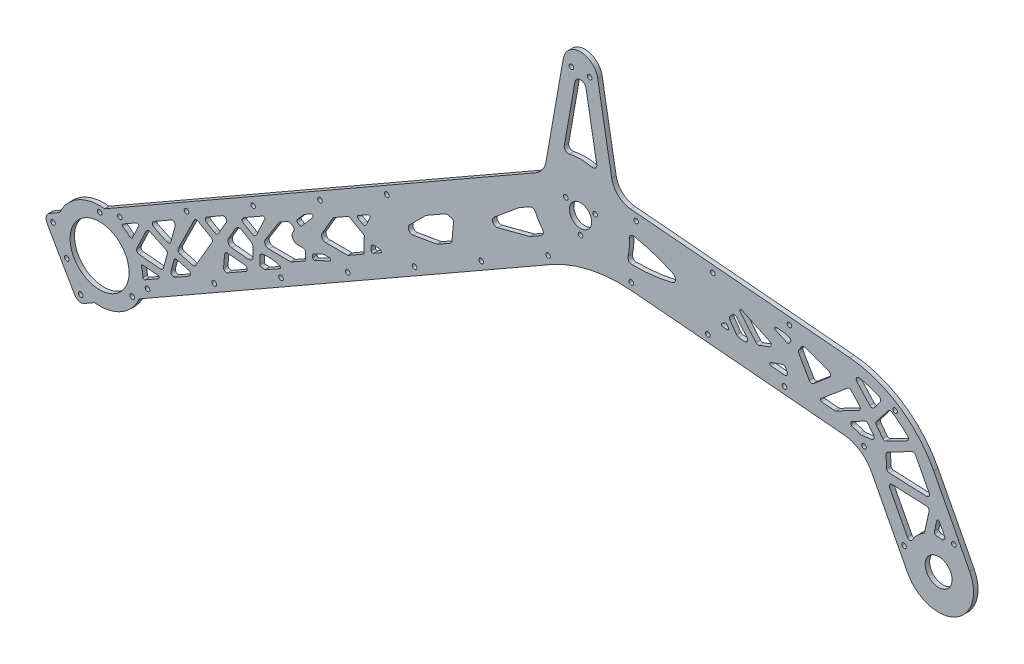
from build123d import *

# Parameters (mm, degrees)
SKETCH2_R                 = 7.9375
SKETCH2_R_2               = 16.05
SKETCH2_R_3               = 1.65
SKETCH2_R_4               = 9.5885
BASE_DEPTH                = 3.175
SKETCH3_R                 = 1.65
STRUT_HOLES_DEPTH         = 4.175
LIGHTENING_HOLES_DEPTH    = 4.175
SKETCH7_R                 = 31.1
SKETCH7_R_2               = 21.1
INNER_MOD_EXTRUSION_DEPTH = 3.175
SKETCH7_2_R               = 21.1
INNER_MOD_CUT_DEPTH       = 4.175
SKETCH8_R                 = 1.65
CUT_EXTRUDE1_DEPTH        = 4.175
FILLET1_R                 = 1
SKETCH9_R                 = 1.65
CUT_EXTRUDE2_DEPTH        = 4.175


with BuildPart() as part:
    # Sketch2 → Base (new body)
    with BuildSketch(Plane.XY):
        with BuildLine():
            Line((-379.716809958, -188.506893436), (-32.006532147, 10.487277971))
            ThreePointArc((-32.006532147, 10.487277971), (-27.186230121, 14.879084252), (-24.685038782, 20.901319377))
            Line((-24.685038782, 20.901319377), (-12.310096913, 91.083102221))
            ThreePointArc((-12.310096913, 91.083102221), (0, 101.4125), (12.310096913, 91.083102221))
            Line((12.310096913, 91.083102221), (22.322003955, 34.302755831))
            ThreePointArc((22.322003955, 34.302755831), (26.960267136, 25.848318444), (35.786784109, 21.964558025))
            Line((35.786784109, 21.964558025), (192.586144941, 8.246391504))
            ThreePointArc((192.586144941, 8.246391504), (227.717231711, -4.10798993), (252.575276723, -31.83706486))
            Line((252.575276723, -31.83706486), (278.255270829, -81.167874559))
            ThreePointArc((278.255270829, -81.167874559), (267.623715331, -114.886860719), (233.904729171, -104.255305221))
            Line((233.904729171, -104.255305221), (208.224735064, -54.924495522))
            ThreePointArc((208.224735064, -54.924495522), (199.93872006, -45.681470545), (188.228357804, -41.563343401))
            Line((188.228357804, -41.563343401), (36.823729736, -28.317154839))
            ThreePointArc((36.823729736, -28.317154839), (6.649577682, -30.266109959), (-21.562664076, -41.144864173))
            Line((-21.562664076, -41.144864173), (-354.881400189, -231.902773674))
            ThreePointArc((-354.881400189, -231.902773674), (-358.677364619, -232.387866435), (-361.70452919, -230.046726627))
            Line((-361.70452919, -230.046726627), (-381.572857005, -195.330022437))
            ThreePointArc((-381.572857005, -195.330022437), (-382.057949767, -191.534058007), (-379.716809958, -188.506893436))
        make_face()
        Circle(SKETCH2_R, mode=Mode.SUBTRACT)
        with Locations((-343.92, -196.825)):
            Circle(SKETCH2_R_2, mode=Mode.SUBTRACT)
        with Locations((-6.5, 88.9125)):
            Circle(SKETCH2_R_3, mode=Mode.SUBTRACT)
        with Locations((6.5, 88.9125)):
            Circle(SKETCH2_R_3, mode=Mode.SUBTRACT)
        with Locations((256.08, -92.71158989)):
            Circle(SKETCH2_R_4, mode=Mode.SUBTRACT)
        with Locations((-365.631063534, -190.919094461)):
            Circle(SKETCH2_R_3, mode=Mode.SUBTRACT)
        with Locations((-338.014094461, -175.113936466)):
            Circle(SKETCH2_R_3, mode=Mode.SUBTRACT)
        with Locations((-322.208936466, -202.730905539)):
            Circle(SKETCH2_R_3, mode=Mode.SUBTRACT)
        with Locations((-349.825905539, -218.536063534)):
            Circle(SKETCH2_R_3, mode=Mode.SUBTRACT)
    extrude(amount=BASE_DEPTH)

    # Sketch3 → Strut Holes (cut, through all)
    with BuildSketch(Plane.XY.offset(3.175)):
        with Locations((-357.364941166, -227.56318565)):
            Circle(SKETCH3_R)
        with Locations((-309.629472905, -200.244234904)):
            Circle(SKETCH3_R)
        with Locations((-261.894004643, -172.925284158)):
            Circle(SKETCH3_R)
        with Locations((-214.158536382, -145.606333412)):
            Circle(SKETCH3_R)
        with Locations((-166.42306812, -118.287382666)):
            Circle(SKETCH3_R)
        with Locations((-118.687599859, -90.96843192)):
            Circle(SKETCH3_R)
        with Locations((-329.49780072, -165.527530714)):
            Circle(SKETCH3_R)
        with Locations((-377.233268981, -192.84648146)):
            Circle(SKETCH3_R)
        with Locations((-281.762332458, -138.208579968)):
            Circle(SKETCH3_R)
        with Locations((-234.026864197, -110.889629222)):
            Circle(SKETCH3_R)
        with Locations((-186.291395936, -83.570678476)):
            Circle(SKETCH3_R)
        with Locations((-138.555927674, -56.25172773)):
            Circle(SKETCH3_R)
        with Locations((36.307361546, -23.252879289)):
            Circle(SKETCH3_R)
        with Locations((91.098069941, -28.04644514)):
            Circle(SKETCH3_R)
        with Locations((145.888778336, -32.840010991)):
            Circle(SKETCH3_R)
        with Locations((149.375008046, 7.007776933)):
            Circle(SKETCH3_R)
        with Locations((94.584299651, 11.801342784)):
            Circle(SKETCH3_R)
        with Locations((39.793591256, 16.594908635)):
            Circle(SKETCH3_R)
        with Locations((-70.952131597, -63.649481174)):
            Circle(SKETCH3_R)
        with Locations((-23.216663336, -36.330530428)):
            Circle(SKETCH3_R)
        with Locations((202.716571226, -41.524122484)):
            Circle(SKETCH3_R)
        with Locations((224.939380546, -8.265337992)):
            Circle(SKETCH3_R)
        with Locations((231.413554138, -88.641399657)):
            Circle(SKETCH3_R)
        with Locations((266.893987465, -70.171455127)):
            Circle(SKETCH3_R)
    extrude(amount=-STRUT_HOLES_DEPTH, mode=Mode.SUBTRACT)

    # Sketch6 → Lightening Holes (cut, through all)
    with BuildSketch(Plane.XY.offset(3.175)):
        with BuildLine():
            Line((-315.269185897, -197.710920307), (-301.759255291, -189.979203363))
            ThreePointArc((-301.759255291, -189.979203363), (-301.27885272, -188.89855459), (-302.165025934, -188.115429161))
            Line((-302.165025934, -188.115429161), (-317.529091672, -186.71244549))
            ThreePointArc((-317.529091672, -186.71244549), (-318.704383169, -186.968323474), (-319.520360019, -187.852045956))
            Line((-319.520360019, -187.852045956), (-321.920665487, -192.94890269))
            ThreePointArc((-321.920665487, -192.94890269), (-322.086706026, -193.488507205), (-322.095332893, -194.053014132))
            ThreePointArc((-322.095332893, -194.053014132), (-322.08483495, -194.136958475), (-322.074659882, -194.220942566))
            ThreePointArc((-322.074659882, -194.220942566), (-321.584640098, -195.311697425), (-320.559879114, -195.927920176))
            ThreePointArc((-320.559879114, -195.927920176), (-318.977814459, -196.521247692), (-317.584009883, -197.476378529))
            ThreePointArc((-317.584009883, -197.476378529), (-316.464213346, -197.964897395), (-315.269185897, -197.710920307))
        make_face()
        with BuildLine():
            Line((-289.844978396, -183.160677107), (-279.93882887, -177.491399715))
            ThreePointArc((-279.93882887, -177.491399715), (-278.948378644, -175.502042811), (-280.407275879, -173.825692191))
            Line((-280.407275879, -173.825692191), (-288.292322007, -171.680779414))
            ThreePointArc((-288.292322007, -171.680779414), (-289.810707779, -171.874816518), (-290.747163702, -173.085682346))
            Line((-290.747163702, -173.085682346), (-292.868560549, -180.884280112))
            ThreePointArc((-292.868560549, -180.884280112), (-292.613471256, -182.502456625), (-291.234784363, -183.387209827))
            ThreePointArc((-291.234784363, -183.387209827), (-291.195764259, -183.393163574), (-291.156778347, -183.399337252))
            ThreePointArc((-291.156778347, -183.399337252), (-290.480404568, -183.392541824), (-289.844978396, -183.160677107))
        make_face()
        with BuildLine():
            Line((-225.068253149, -146.0890356), (-215.065938543, -140.36472305))
            ThreePointArc((-215.065938543, -140.36472305), (-214.567033215, -139.40324417), (-215.236329185, -138.55154524))
            ThreePointArc((-215.236329185, -138.55154524), (-221.331874052, -137.268264968), (-227.555460503, -137.531793255))
            ThreePointArc((-227.555460503, -137.531793255), (-228.747493021, -138.209832448), (-229.222550686, -139.49630005))
            Line((-229.222550686, -139.49630005), (-229.243920799, -145.124584195))
            ThreePointArc((-229.243920799, -145.124584195), (-228.903638362, -145.87990104), (-228.110599563, -146.11945299))
            ThreePointArc((-228.110599563, -146.11945299), (-226.935128796, -146.061146676), (-225.766503733, -146.200597789))
            ThreePointArc((-225.766503733, -146.200597789), (-225.407188584, -146.208593442), (-225.068253149, -146.0890356))
        make_face()
        with BuildLine():
            Line((-202.41887229, -105.511400104), (-200.686234771, -106.520529682))
            ThreePointArc((-200.686234771, -106.520529682), (-200.013042452, -106.64186894), (-199.419351845, -106.302100524))
            Line((-199.419351845, -106.302100524), (-191.360868047, -96.772094027))
            ThreePointArc((-191.360868047, -96.772094027), (-191.355986863, -95.486528074), (-192.621174572, -95.258484862))
            Line((-192.621174572, -95.258484862), (-197.478989202, -98.038606299))
            ThreePointArc((-197.478989202, -98.038606299), (-197.765321596, -98.237482482), (-198.01276947, -98.483058387))
            Line((-198.01276947, -98.483058387), (-202.679186023, -104.001587826))
            ThreePointArc((-202.679186023, -104.001587826), (-202.901047671, -104.817187109), (-202.41887229, -105.511400104))
        make_face()
        with BuildLine():
            Line((-330.425499061, -170.667183769), (-317.378257487, -163.200263197))
            ThreePointArc((-317.378257487, -163.200263197), (-316.203164595, -163.333473919), (-315.976852671, -164.494237166))
            Line((-315.976852671, -164.494237166), (-323.402158767, -180.26128093))
            ThreePointArc((-323.402158767, -180.26128093), (-324.218135617, -181.145003412), (-325.393427114, -181.400881396))
            Line((-325.393427114, -181.400881396), (-327.826064744, -181.178742873))
            ThreePointArc((-327.826064744, -181.178742873), (-328.456346912, -181.014705953), (-329.000507167, -180.656860539))
            ThreePointArc((-329.000507167, -180.656860539), (-329.788551481, -179.963737807), (-330.608754561, -179.308986045))
            ThreePointArc((-330.608754561, -179.308986045), (-331.300981929, -178.333954341), (-331.313186478, -177.138246768))
            ThreePointArc((-331.313186478, -177.138246768), (-331.014233087, -175.069882607), (-331.339196402, -173.005445087))
            ThreePointArc((-331.339196402, -173.005445087), (-331.294912573, -171.675100882), (-330.425499061, -170.667183769))
        make_face()
        with BuildLine():
            Line((-295.53330948, -171.631597975), (-298.296173769, -181.788333758))
            ThreePointArc((-298.296173769, -181.788333758), (-299.085121934, -182.906012266), (-300.407921189, -183.255077571))
            Line((-300.407921189, -183.255077571), (-315.662540801, -181.862088072))
            ThreePointArc((-315.662540801, -181.862088072), (-317.216500905, -180.86379127), (-317.290058936, -179.018262152))
            Line((-317.290058936, -179.018262152), (-310.641451377, -164.900475625))
            ThreePointArc((-310.641451377, -164.900475625), (-309.508957679, -163.870619434), (-307.979945409, -163.943195111))
            Line((-307.979945409, -163.943195111), (-296.611069066, -169.297235353))
            ThreePointArc((-296.611069066, -169.297235353), (-295.647370018, -170.26828046), (-295.53330948, -171.631597975))
        make_face()
        with BuildLine():
            Line((-292.778723285, -149.121979529), (-305.215642876, -156.239613568))
            ThreePointArc((-305.215642876, -156.239613568), (-306.220639762, -158.055100377), (-305.074339213, -159.784842018))
            Line((-305.074339213, -159.784842018), (-295.766029178, -164.168482495))
            ThreePointArc((-295.766029178, -164.168482495), (-294.075568316, -164.17490103), (-292.984044137, -162.884058635))
            Line((-292.984044137, -162.884058635), (-289.85543458, -151.38278412))
            ThreePointArc((-289.85543458, -151.38278412), (-290.561768266, -149.275742292), (-292.778723285, -149.121979529))
        make_face()
        with BuildLine():
            Line((-286.412158457, -167.010536912), (-277.477694151, -169.440915421))
            ThreePointArc((-277.477694151, -169.440915421), (-276.194379154, -169.361694864), (-275.224483334, -168.5176123))
            Line((-275.224483334, -168.5176123), (-263.487039881, -148.364863469))
            ThreePointArc((-263.487039881, -148.364863469), (-263.281478176, -146.847994939), (-264.208712124, -145.63005284))
            Line((-264.208712124, -145.63005284), (-273.491108909, -140.223762697))
            ThreePointArc((-273.491108909, -140.223762697), (-275.075155334, -140.037188202), (-276.291924346, -141.06844292))
            Line((-276.291924346, -141.06844292), (-287.68143532, -164.197103385))
            ThreePointArc((-287.68143532, -164.197103385), (-287.710247586, -165.903135064), (-286.412158457, -167.010536912))
        make_face()
        with BuildLine():
            Line((-267.326941544, -134.555955625), (-255.981699002, -128.063087041))
            ThreePointArc((-255.981699002, -128.063087041), (-253.568709634, -128.390088491), (-253.260041176, -130.805491443))
            Line((-253.260041176, -130.805491443), (-258.957478514, -140.587777008))
            ThreePointArc((-258.957478514, -140.587777008), (-260.175420613, -141.515010956), (-261.692289142, -141.309449251))
            Line((-261.692289142, -141.309449251), (-267.340094346, -138.02003227))
            ThreePointArc((-267.340094346, -138.02003227), (-268.333510737, -136.284197061), (-267.326941544, -134.555955625))
        make_face()
        with BuildLine():
            Line((-255.261313261, -159.742391016), (-254.488576255, -151.280152708))
            ThreePointArc((-254.488576255, -151.280152708), (-253.776611846, -149.925068788), (-252.314987955, -149.470314621))
            Line((-252.314987955, -149.470314621), (-240.229659184, -150.573897437))
            ThreePointArc((-240.229659184, -150.573897437), (-238.457312757, -152.140148294), (-239.418117899, -154.30144584))
            Line((-239.418117899, -154.30144584), (-252.276183677, -161.660101332))
            ThreePointArc((-252.276183677, -161.660101332), (-254.350596062, -161.606956723), (-255.261313261, -159.742391016))
        make_face()
        with BuildLine():
            Line((-246.540160509, -131.189393308), (-251.794794147, -140.211401578))
            ThreePointArc((-251.794794147, -140.211401578), (-251.868704934, -143.096387582), (-249.475244653, -144.708825158))
            Line((-249.475244653, -144.708825158), (-237.508018237, -145.801623349))
            ThreePointArc((-237.508018237, -145.801623349), (-235.21684764, -145.033565045), (-234.235227202, -142.825444219))
            Line((-234.235227202, -142.825444219), (-234.211718457, -136.633904573))
            ThreePointArc((-234.211718457, -136.633904573), (-234.607944018, -135.132389326), (-235.701843043, -134.030151758))
            Line((-235.701843043, -134.030151758), (-242.437944567, -130.106884943))
            ThreePointArc((-242.437944567, -130.106884943), (-244.713247361, -129.798542386), (-246.540160509, -131.189393308))
        make_face()
        with BuildLine():
            Line((-241.753564235, -124.719255848), (-234.63976684, -128.862501783))
            ThreePointArc((-234.63976684, -128.862501783), (-233.039032694, -129.043963991), (-231.823804406, -127.986373074))
            Line((-231.823804406, -127.986373074), (-225.796901327, -115.1887263))
            ThreePointArc((-225.796901327, -115.1887263), (-226.023213251, -114.027963054), (-227.198306143, -113.894752332))
            Line((-227.198306143, -113.894752332), (-240.486863137, -121.499777426))
            ThreePointArc((-240.486863137, -121.499777426), (-240.868014227, -121.782834524), (-241.171709307, -122.147754751))
            ThreePointArc((-241.171709307, -122.147754751), (-241.549582312, -122.675396768), (-241.974698217, -123.165774758))
            ThreePointArc((-241.974698217, -123.165774758), (-242.240299662, -123.996061899), (-241.753564235, -124.719255848))
        make_face()
        with BuildLine():
            Line((-215.668807888, -112.174898455), (-225.379976009, -127.585503674))
            ThreePointArc((-225.379976009, -127.585503674), (-225.4712487, -130.629365716), (-222.853276851, -132.184888211))
            Line((-222.853276851, -132.184888211), (-207.454371398, -132.243356535))
            ThreePointArc((-207.454371398, -132.243356535), (-206.936478287, -132.177174092), (-206.453361233, -131.979206161))
            Line((-206.453361233, -131.979206161), (-197.505650544, -126.858442157))
            ThreePointArc((-197.505650544, -126.858442157), (-196.770825499, -126.12917614), (-196.499081351, -125.130200721))
            Line((-196.499081351, -125.130200721), (-196.484480993, -121.28487852))
            ThreePointArc((-196.484480993, -121.28487852), (-197.064893599, -119.868450986), (-198.476872802, -119.277299162))
            Line((-198.476872802, -119.277299162), (-202.260748213, -119.262932112))
            ThreePointArc((-202.260748213, -119.262932112), (-205.751377346, -117.188902119), (-205.629680425, -113.130419396))
            Line((-205.629680425, -113.130419396), (-205.026921593, -112.173904352))
            ThreePointArc((-205.026921593, -112.173904352), (-204.776566908, -110.63116148), (-205.712412279, -109.379392142))
            Line((-205.712412279, -109.379392142), (-207.46181523, -108.360497976))
            ThreePointArc((-207.46181523, -108.360497976), (-208.460790649, -108.088753828), (-209.461800813, -108.352904202))
            Line((-209.461800813, -108.352904202), (-214.9701644, -111.50533402))
            ThreePointArc((-214.9701644, -111.50533402), (-215.360592232, -111.79722492), (-215.668807888, -112.174898455))
        make_face()
        with BuildLine():
            Line((-191.479772218, -120.054212502), (-191.486581073, -121.847472571))
            ThreePointArc((-191.486581073, -121.847472571), (-191.027086278, -122.692614758), (-190.067414214, -122.759175345))
            Line((-190.067414214, -122.759175345), (-179.245533818, -117.762785652))
            ThreePointArc((-179.245533818, -117.762785652), (-178.687597118, -116.642148596), (-179.660910998, -115.854886972))
            Line((-179.660910998, -115.854886972), (-183.284876561, -115.841127086))
            ThreePointArc((-183.284876561, -115.841127086), (-183.717932672, -115.886891136), (-184.13081847, -116.025300894))
            Line((-184.13081847, -116.025300894), (-190.898953493, -119.150103501))
            ThreePointArc((-190.898953493, -119.150103501), (-191.321124727, -119.517511391), (-191.479772218, -120.054212502))
        make_face()
        with BuildLine():
            Line((-166.401123038, -107.905175585), (-182.204856698, -107.845170163))
            ThreePointArc((-182.204856698, -107.845170163), (-184.797218852, -106.335316373), (-184.785828191, -103.335337998))
            Line((-184.785828191, -103.335337998), (-176.831995141, -89.678905885))
            Line((-176.831995141, -89.678905885), (-165.638950905, -83.273140207))
            Line((-165.638950905, -83.273140207), (-154.64049223, -89.678905885))
            Line((-154.64049223, -89.678905885), (-154.684235374, -101.199614947))
            Line((-154.684235374, -101.199614947), (-166.401123038, -107.905175585))
        make_face()
        with BuildLine():
            Line((-149.666734346, -96.599830521), (-149.657550536, -94.181074309))
            ThreePointArc((-149.657550536, -94.181074309), (-149.003136911, -92.708993759), (-147.475689846, -92.196954889))
            Line((-147.475689846, -92.196954889), (-143.284670701, -92.579661624))
            ThreePointArc((-143.284670701, -92.579661624), (-142.398497488, -93.362787052), (-142.878900059, -94.443435825))
            Line((-142.878900059, -94.443435825), (-148.170033359, -97.471545013))
            ThreePointArc((-148.170033359, -97.471545013), (-149.170026151, -97.467748126), (-149.666734346, -96.599830521))
        make_face()
        with BuildLine():
            Line((-159.124748889, -79.545070273), (-152.013980011, -75.475585845))
            ThreePointArc((-152.013980011, -75.475585845), (-150.838887119, -75.608796567), (-150.612575195, -76.769559813))
            Line((-150.612575195, -76.769559813), (-153.182146906, -82.225839878))
            ThreePointArc((-153.182146906, -82.225839878), (-154.397375194, -83.283430795), (-155.99810934, -83.101968586))
            Line((-155.99810934, -83.101968586), (-159.13132529, -81.277108596))
            ThreePointArc((-159.13132529, -81.277108596), (-159.628033486, -80.409190991), (-159.124748889, -79.545070273))
        make_face()
        with BuildLine():
            Line((-90.819864813, -49.698540482), (-91.896421351, -61.487904644))
            ThreePointArc((-91.896421351, -61.487904644), (-92.359955239, -62.836585977), (-93.393866555, -63.818844799))
            Line((-93.393866555, -63.818844799), (-101.994338017, -68.740884214))
            ThreePointArc((-101.994338017, -68.740884214), (-102.469113289, -68.960084777), (-102.974739436, -69.09351133))
            Line((-102.974739436, -69.09351133), (-119.629879497, -71.965101226))
            ThreePointArc((-119.629879497, -71.965101226), (-122.805875604, -70.383853511), (-122.252853304, -66.87936183))
            Line((-122.252853304, -66.87936183), (-110.681116507, -55.395166432))
            ThreePointArc((-110.681116507, -55.395166432), (-110.385100172, -55.137548838), (-110.057990454, -54.920773084))
            Line((-110.057990454, -54.920773084), (-96.724691463, -47.290142199))
            ThreePointArc((-96.724691463, -47.290142199), (-95.614849419, -46.918095089), (-94.447112805, -46.999086542))
            Line((-94.447112805, -46.999086542), (-92.286608626, -47.586793062))
            ThreePointArc((-92.286608626, -47.586793062), (-91.168930118, -48.375741228), (-90.819864813, -49.698540482))
        make_face()
        with BuildLine():
            Line((-28.096781534, -26.449402024), (-35.825401618, -30.87248195))
            ThreePointArc((-35.825401618, -30.87248195), (-36.178007781, -31.044706772), (-36.550077199, -31.169433846))
            Line((-36.550077199, -31.169433846), (-59.133973609, -37.128958431))
            ThreePointArc((-59.133973609, -37.128958431), (-62.565695554, -35.603385935), (-61.819045791, -31.92281518))
            Line((-61.819045791, -31.92281518), (-44.317223042, -17.349924163))
            ThreePointArc((-44.317223042, -17.349924163), (-44.108986088, -17.191390869), (-43.887724451, -17.051609889))
            Line((-43.887724451, -17.051609889), (-36.274597881, -12.694626761))
            ThreePointArc((-36.274597881, -12.694626761), (-33.845543285, -12.449097133), (-32.038330666, -14.090612767))
            ThreePointArc((-32.038330666, -14.090612767), (-29.904900702, -18.185073934), (-27.251097742, -21.963097956))
            ThreePointArc((-27.251097742, -21.963097956), (-26.638826778, -24.401372335), (-28.096781534, -26.449402024))
        make_face()
        with BuildLine():
            Line((-11.599665343, 37.524455033), (-3.986146646, 80.702865203))
            ThreePointArc((-3.986146646, 80.702865203), (0, 84.047639383), (3.986146646, 80.702865203))
            Line((3.986146646, 80.702865203), (11.599665343, 37.524455033))
            ThreePointArc((11.599665343, 37.524455033), (10.707449692, 34.824680589), (7.962722972, 34.082180723))
            ThreePointArc((7.962722972, 34.082180723), (0, 35), (-7.962722972, 34.082180723))
            ThreePointArc((-7.962722972, 34.082180723), (-10.707449692, 34.824680589), (-11.599665343, 37.524455033))
        make_face()
        with BuildLine():
            Line((246.075987756, -72.913561708), (249.254007124, -58.57844272))
            ThreePointArc((249.254007124, -58.57844272), (248.888121791, -56.928040634), (247.388653885, -56.147467049))
            Line((247.388653885, -56.147467049), (222.962162816, -55.080983417))
            ThreePointArc((222.962162816, -55.080983417), (221.188141149, -56.004480644), (221.100902375, -58.002577087))
            Line((221.100902375, -58.002577087), (233.735290203, -82.273010289))
            ThreePointArc((233.735290203, -82.273010289), (235.484637714, -83.349360854), (237.260008731, -82.316498325))
            ThreePointArc((237.260008731, -82.316498325), (240.657318696, -77.731906936), (245.140979083, -74.202461834))
            ThreePointArc((245.140979083, -74.202461834), (245.742284649, -73.655075389), (246.075987756, -72.913561708))
        make_face()
        with BuildLine():
            Line((253.133679234, -68.799730633), (254.751992566, -61.499990928))
            ThreePointArc((254.751992566, -61.499990928), (255.597762381, -60.72498568), (256.615299406, -61.254681929))
            Line((256.615299406, -61.254681929), (260.345615198, -68.420551892))
            ThreePointArc((260.345615198, -68.420551892), (260.223925452, -70.470902803), (258.359543018, -71.332775993))
            ThreePointArc((258.359543018, -71.332775993), (256.767087179, -71.222571503), (255.170843908, -71.230820928))
            ThreePointArc((255.170843908, -71.230820928), (253.553325039, -70.51716267), (253.133679234, -68.799730633))
        make_face()
        with BuildLine():
            Line((249.310771487, -47.22281435), (239.59747458, -28.563744597))
            ThreePointArc((239.59747458, -28.563744597), (238.424864512, -27.579807922), (236.899955687, -27.713220157))
            Line((236.899955687, -27.713220157), (219.565597936, -36.736915644))
            ThreePointArc((219.565597936, -36.736915644), (218.757044355, -37.510937311), (218.490998719, -38.598176086))
            Line((218.490998719, -38.598176086), (218.860832904, -47.068771554))
            ThreePointArc((218.860832904, -47.068771554), (219.444715785, -48.395746342), (220.771690573, -48.979629223))
            Line((220.771690573, -48.979629223), (247.449511046, -50.144408019))
            ThreePointArc((247.449511046, -50.144408019), (249.223532712, -49.220910793), (249.310771487, -47.22281435))
        make_face()
        with BuildLine():
            Line((233.413458883, -22.763883833), (218.618137266, -30.46584077))
            ThreePointArc((218.618137266, -30.46584077), (217.261760811, -30.644411118), (216.107933359, -29.909341962))
            Line((216.107933359, -29.909341962), (211.671799483, -24.128059737))
            ThreePointArc((211.671799483, -24.128059737), (211.258506163, -22.910536879), (211.671799483, -21.693014021))
            Line((211.671799483, -21.693014021), (220.007167815, -10.830150518))
            ThreePointArc((220.007167815, -10.830150518), (221.257760997, -10.076118732), (222.687548657, -10.3731953))
            ThreePointArc((222.687548657, -10.3731953), (228.553817552, -14.676513168), (233.918900039, -19.590528361))
            ThreePointArc((233.918900039, -19.590528361), (234.465065341, -21.304449895), (233.413458883, -22.763883833))
        make_face()
        with BuildLine():
            Line((209.61657846, -31.305721344), (205.746256457, -26.261819508))
            ThreePointArc((205.746256457, -26.261819508), (204.592429004, -25.526750352), (203.23605255, -25.7053207))
            Line((203.23605255, -25.7053207), (194.010059092, -30.508068903))
            ThreePointArc((194.010059092, -30.508068903), (193.616895834, -30.876306478), (193.471807705, -31.395079736))
            Line((193.471807705, -31.395079736), (193.471807705, -32.496691451))
            ThreePointArc((193.471807705, -32.496691451), (193.684204256, -33.112873898), (194.23116932, -33.467306291))
            ThreePointArc((194.23116932, -33.467306291), (196.89746606, -34.245224393), (199.491371204, -35.238175037))
            ThreePointArc((199.491371204, -35.238175037), (200.2654041, -35.454155852), (201.069000396, -35.456918226))
            Line((201.069000396, -35.456918226), (208.290924164, -34.506133925))
            ThreePointArc((208.290924164, -34.506133925), (209.877630844, -33.288611067), (209.61657846, -31.305721344))
        make_face()
        with BuildLine():
            Line((214.303083467, -8.407780179), (209.957683706, -14.070815403))
            ThreePointArc((209.957683706, -14.070815403), (208.4582158, -14.851388988), (206.896422352, -14.20447296))
            Line((206.896422352, -14.20447296), (197.688681904, -4.155987535))
            ThreePointArc((197.688681904, -4.155987535), (197.423723958, -1.817844179), (199.566737265, -0.845933158))
            ThreePointArc((199.566737265, -0.845933158), (206.676023639, -2.722269436), (213.536897173, -5.366320289))
            ThreePointArc((213.536897173, -5.366320289), (214.655785228, -6.701693203), (214.303083467, -8.407780179))
        make_face()
        with BuildLine():
            Line((193.681402215, -11.624307007), (199.545514004, -18.023862053))
            ThreePointArc((199.545514004, -18.023862053), (200.040574836, -19.722338824), (198.994456557, -21.149064135))
            Line((198.994456557, -21.149064135), (182.807531418, -29.575444012))
            ThreePointArc((182.807531418, -29.575444012), (182.007556544, -29.856767353), (181.16081835, -29.902995606))
            Line((181.16081835, -29.902995606), (172.48260155, -29.143750017))
            ThreePointArc((172.48260155, -29.143750017), (171.616040342, -28.448261118), (171.926969683, -27.381510875))
            Line((171.926969683, -27.381510875), (190.921272322, -11.443398536))
            ThreePointArc((190.921272322, -11.443398536), (192.3376538, -10.979769576), (193.681402215, -11.624307007))
        make_face()
        with BuildLine():
            Line((178.199205815, -11.022517891), (166.591800736, -20.762287211))
            ThreePointArc((166.591800736, -20.762287211), (164.958929162, -21.199813831), (163.574174709, -20.230198325))
            Line((163.574174709, -20.230198325), (156.047951006, -7.194396481))
            ThreePointArc((156.047951006, -7.194396481), (155.78190537, -6.107157706), (156.141697725, -5.047243608))
            Line((156.141697725, -5.047243608), (158.18845934, -2.124165087))
            ThreePointArc((158.18845934, -2.124165087), (159.22535183, -1.363884058), (160.510803716, -1.391932718))
            Line((160.510803716, -1.391932718), (177.597670882, -7.611043763))
            ThreePointArc((177.597670882, -7.611043763), (178.883246101, -9.143132649), (178.199205815, -11.022517891))
        make_face()
        with BuildLine():
            Line((146.644806866, -20.907673079), (147.746965574, -22.816667961))
            ThreePointArc((147.746965574, -22.816667961), (147.701697658, -24.891267177), (145.840603281, -25.809057357))
            Line((145.840603281, -25.809057357), (136.229987031, -24.968237386))
            ThreePointArc((136.229987031, -24.968237386), (135.325697913, -24.10256888), (135.975122631, -23.032350067))
            Line((135.975122631, -23.032350067), (144.228715771, -20.028287838))
            ThreePointArc((144.228715771, -20.028287838), (145.596796345, -20.028287838), (146.644806866, -20.907673079))
        make_face()
        with BuildLine():
            Line((134.974345297, -13.819003275), (127.671845659, -16.476895779))
            ThreePointArc((127.671845659, -16.476895779), (126.470167282, -16.52936219), (125.455716486, -15.883085757))
            Line((125.455716486, -15.883085757), (114.198527576, -2.46729043))
            ThreePointArc((114.198527576, -2.46729043), (114.171218678, -1.215741392), (115.387190281, -0.918195034))
            Line((115.387190281, -0.918195034), (135.135541534, -10.127002459))
            ThreePointArc((135.135541534, -10.127002459), (136.288401454, -12.026856808), (134.974345297, -13.819003275))
        make_face()
        with BuildLine():
            Line((139.430597275, -1.096040654), (147.83182135, -5.013595778))
            ThreePointArc((147.83182135, -5.013595778), (148.513258657, -5.073213817), (149.073591656, -4.680864427))
            Line((149.073591656, -4.680864427), (150.425898479, -2.749570135))
            ThreePointArc((150.425898479, -2.749570135), (150.560463385, -1.875287899), (149.948766578, -1.236301077))
            Line((149.948766578, -1.236301077), (146.098496258, 0.165082713))
            ThreePointArc((146.098496258, 0.165082713), (145.72175467, 0.274892872), (145.333903056, 0.334588945))
            Line((145.333903056, 0.334588945), (139.940371279, 0.806461832))
            ThreePointArc((139.940371279, 0.806461832), (138.88728971, 0.069086179), (139.430597275, -1.096040654))
        make_face()
        with BuildLine():
            Line((111.660494937, -7.221200049), (119.04545342, -16.022250853))
            ThreePointArc((119.04545342, -16.022250853), (119.2873862, -18.231323299), (117.339053048, -19.300215468))
            Line((117.339053048, -19.300215468), (113.116226003, -18.930765974))
            ThreePointArc((113.116226003, -18.930765974), (112.290537488, -18.670427385), (111.6522334, -18.08552945))
            Line((111.6522334, -18.08552945), (106.877510971, -11.266519132))
            ThreePointArc((106.877510971, -11.266519132), (106.523425664, -9.945054773), (107.101601497, -8.705152697))
            Line((107.101601497, -8.705152697), (108.714192488, -7.092561706))
            ThreePointArc((108.714192488, -7.092561706), (110.215644825, -6.508678825), (111.660494937, -7.221200049))
        make_face()
        with BuildLine():
            Line((104.703890017, -15.136053881), (105.75536165, -16.637710998))
            ThreePointArc((105.75536165, -16.637710998), (105.80223501, -17.711287434), (104.849053863, -18.207482132))
            Line((104.849053863, -18.207482132), (101.67727128, -17.929987113))
            ThreePointArc((101.67727128, -17.929987113), (100.788131016, -17.150232029), (101.264427023, -16.067767011))
            Line((101.264427023, -16.067767011), (103.384737973, -14.843604914))
            ThreePointArc((103.384737973, -14.843604914), (104.101177587, -14.73333431), (104.703890017, -15.136053881))
        make_face()
        with BuildLine():
            ThreePointArc((34.863622447, 3.086718303), (34.900341082, -2.63935454), (34.002891304, -8.294780463))
            ThreePointArc((34.002891304, -8.294780463), (34.552114447, -10.851108963), (36.89804352, -12.005699039))
            ThreePointArc((36.89804352, -12.005699039), (51.290024205, -11.233136631), (65.485577957, -8.740705208))
            ThreePointArc((65.485577957, -8.740705208), (67.910545504, -5.973310403), (66.09771963, -2.77134164))
            ThreePointArc((66.09771963, -2.77134164), (52.541526947, 2.603547383), (38.433463256, 6.29439159))
            ThreePointArc((38.433463256, 6.29439159), (35.846829531, 5.582787002), (34.863622447, 3.086718303))
        make_face()
    extrude(amount=-LIGHTENING_HOLES_DEPTH, mode=Mode.SUBTRACT)

    # Sketch7 → Inner Mod Extrusion (add)
    with BuildSketch(Plane.XY.offset(3.175)):
        with Locations((-343.92, -196.825)):
            Circle(SKETCH7_R)
        with Locations((-343.92, -196.825)):
            Circle(SKETCH7_R_2, mode=Mode.SUBTRACT)
    extrude(amount=-INNER_MOD_EXTRUSION_DEPTH)

    # Sketch7_2 → Inner Mod Cut (cut, through all)
    with BuildSketch(Plane.XY.offset(3.175)):
        with Locations((-343.92, -196.825)):
            Circle(SKETCH7_2_R)
    extrude(amount=-INNER_MOD_CUT_DEPTH, mode=Mode.SUBTRACT)

    # Sketch8 → Cut-Extrude1 (cut, through all)
    with BuildSketch(Plane.XY.offset(3.175)):
        with Locations((-10.5, 6.062177826)):
            Circle(SKETCH8_R)
        with Locations((10.5, 6.062177826)):
            Circle(SKETCH8_R)
        with Locations((0, -12.124355653)):
            Circle(SKETCH8_R)
    extrude(amount=-CUT_EXTRUDE1_DEPTH, mode=Mode.SUBTRACT)

    # Fillet1
    fillet1_edges = [part.edges().sort_by_distance(p)[0] for p in [
        (-321.200874806, -175.587030455, 1.5875),
        (-328.721252458, -169.691845499, 1.5875),
        (-314.413747071, -186.996926023, 1.5875),
        (-312.824236602, -196.311678782, 1.5875),
    ]]
    fillet(fillet1_edges, radius=FILLET1_R)

    # Sketch9 → Cut-Extrude2 (cut, through all)
    with BuildSketch(Plane.XY.offset(3.175)):
        with Locations((-367.353775328, -210.236121275)):
            Circle(SKETCH9_R)
        with Locations((-343.817484053, -169.825194621)):
            Circle(SKETCH9_R)
        with Locations((-320.588740618, -210.413684103)):
            Circle(SKETCH9_R)
    extrude(amount=-CUT_EXTRUDE2_DEPTH, mode=Mode.SUBTRACT)


solid = part.part
